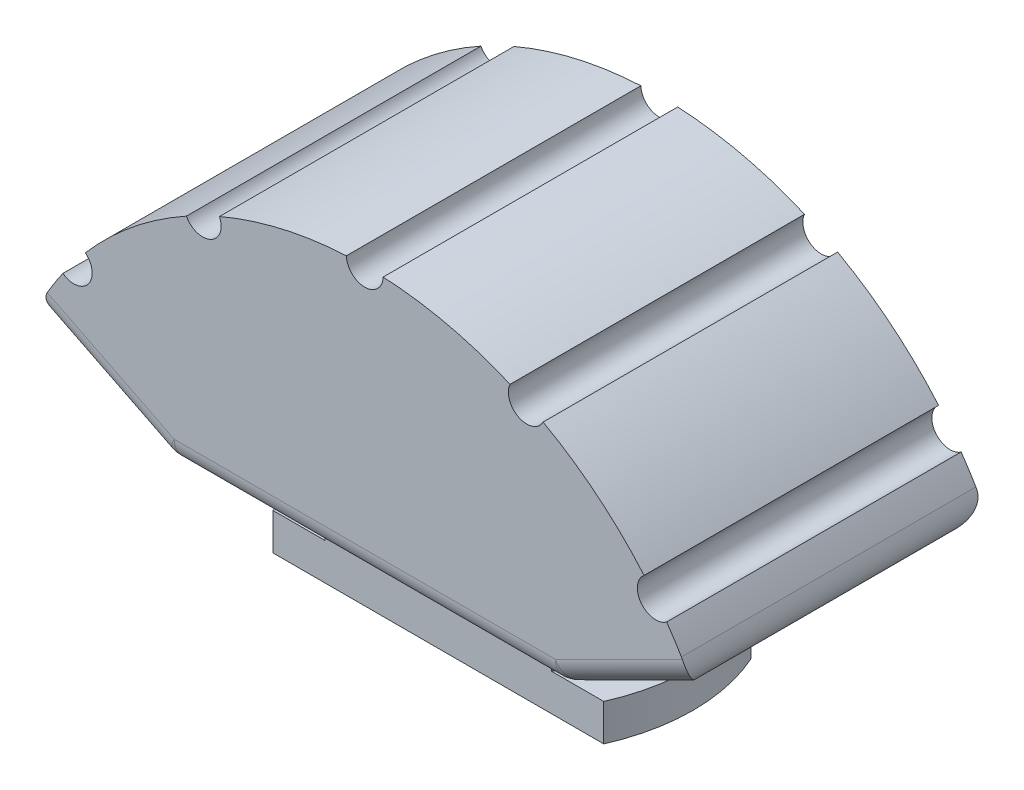
from build123d import *

# Parameters (mm, degrees)
SKETCH1_W           = 29.5
SKETCH1_H           = 12
BOSS_EXTRUDE1_DEPTH = 3
BOSS_EXTRUDE7_DEPTH = 12
BOSS_EXTRUDE8_DEPTH = 5
SKETCH16_R          = 1.5
CUT_EXTRUDE11_DEPTH = 24
FILLET5_R           = 2
SKETCH17_OUTSIDE_W  = 67.126
SKETCH17_OUTSIDE_H  = 38.954
SKETCH17_OUTSIDE_R  = 14.75
CUT_EXTRUDE12_DEPTH = 3


with BuildPart() as part:
    # Sketch1 → Boss-Extrude1 (new body)
    with BuildSketch(Plane(origin=(0, 0, 0), x_dir=(1, 0, 0), z_dir=(0, 1, 0))):
        Rectangle(SKETCH1_W, SKETCH1_H)
    extrude(amount=BOSS_EXTRUDE1_DEPTH)



with BuildPart() as body_2:
    # Sketch14 → Boss-Extrude7 (new body, symmetric)
    with BuildSketch(Plane.XY):
        with BuildLine():
            Line((-26.83281573, 13.416407865), (-16, 8))
            Line((-16, 8), (16, 8))
            Line((16, 8), (26.83281573, 13.416407865))
            ThreePointArc((26.83281573, 13.416407865), (0, 30), (-26.83281573, 13.416407865))
        make_face()
    extrude(amount=BOSS_EXTRUDE7_DEPTH, both=True)


with BuildPart() as part_1:
    add(part.part)

    add(body_2.part)  # Boss-Extrude8 merges body 2
    # Sketch15 → Boss-Extrude8 (add)
    with BuildSketch(Plane(origin=(0, 3, 0), x_dir=(-1, 0, 0), z_dir=(0, 1, 0))):
        with BuildLine():
            Line((-9.219544457, 6), (9.219544457, 6))
            ThreePointArc((9.219544457, 6), (11, 0), (9.219544457, -6))
            Line((9.219544457, -6), (-9.219544457, -6))
            ThreePointArc((-9.219544457, -6), (-11, 0), (-9.219544457, 6))
        make_face()
    extrude(amount=BOSS_EXTRUDE8_DEPTH)

    # Sketch16 → Cut-Extrude11 (cut)
    with BuildSketch(Plane(origin=(0, 0, -12), x_dir=(-1, 0, 0), z_dir=(0, 0, -1))):
        with Locations((-23.713219718, 18.376158756)):
            Circle(SKETCH16_R)
        with Locations((-13.204454501, 26.937750117)):
            Circle(SKETCH16_R)
        with Locations((0, 30)):
            Circle(SKETCH16_R)
        with Locations((13.204454501, 26.937750117)):
            Circle(SKETCH16_R)
        with Locations((23.713219718, 18.376158756)):
            Circle(SKETCH16_R)
    extrude(amount=-CUT_EXTRUDE11_DEPTH, mode=Mode.SUBTRACT)

    # Fillet5
    fillet5_edges = [part_1.edges().sort_by_distance(p)[0] for p in [
        (26.83281573, 13.416407865, 0),
        (-21.416407865, 10.708203932, -12),
        (-26.83281573, 13.416407865, 0),
        (0, 8, -12),
        (-16, 8, 0),
        (21.416407865, 10.708203932, -12),
        (16, 8, 0),
        (-21.416407865, 10.708203932, 12),
        (0, 8, 12),
        (21.416407865, 10.708203932, 12),
    ]]
    fillet(fillet5_edges, radius=FILLET5_R)

    # Sketch17 outside → Cut-Extrude12 (cut)
    with BuildSketch(Plane.XZ):
        Rectangle(SKETCH17_OUTSIDE_W, SKETCH17_OUTSIDE_H)
        Circle(SKETCH17_OUTSIDE_R, mode=Mode.SUBTRACT)
    extrude(amount=-CUT_EXTRUDE12_DEPTH, mode=Mode.SUBTRACT)


solid = part_1.part
